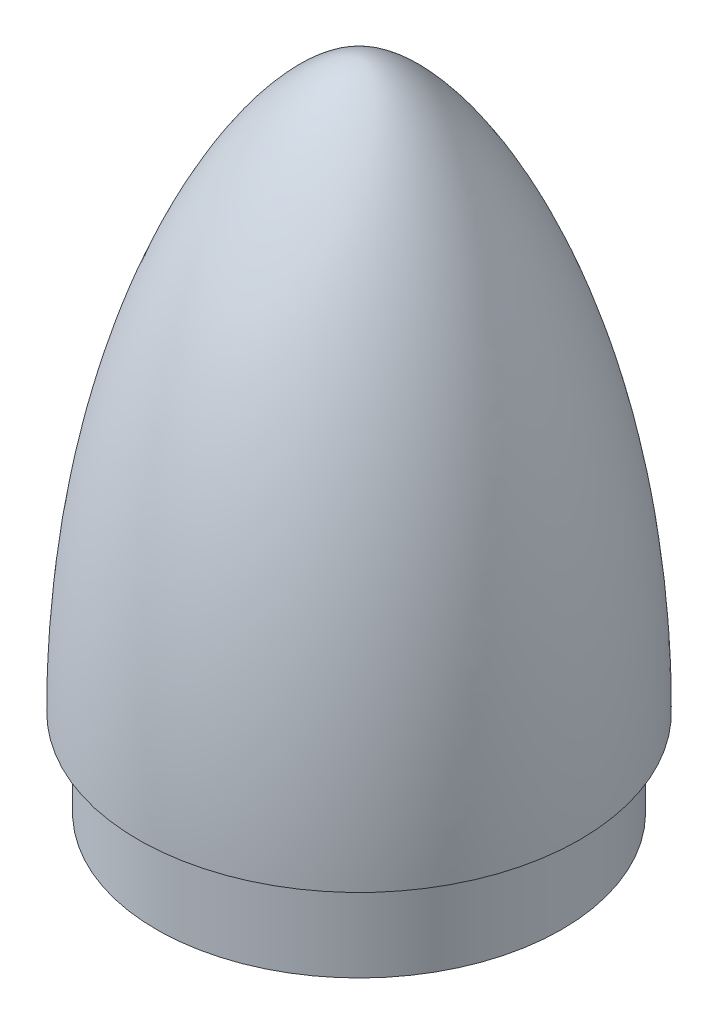
from build123d import *

# Parameters (mm, degrees)
THICKEN1_T1         = 1.2
BOSS_EXTRUDE7_REACH = 75.217
SKETCH5_W           = 21
SKETCH5_H           = 3.5
CUT_EXTRUDE1_DEPTH  = 2


with BuildPart() as body_1:
    # Surface-Revolve1: a surface, the sketch's curves turned about an axis
    with BuildLine(Plane.XY, mode=Mode.PRIVATE) as surface_revolve1_1_path:
        Line((23.3, 0), (23.3, 10))
        Line((23.3, 10), (25.4, 10))
        add(Edge.make_bspline(
            [(25.4, 10), (25.4, 50), (8.333333333, 75), (0, 75)],
            knots=[0, 0, 0, 0, 1, 1, 1, 1], degree=3))
    surface_revolve1_1 = Shell.revolve(surface_revolve1_1_path.wire(), 360, Axis((0, 75, 0), (0, -1, 0)))
    add(Solid.thicken(surface_revolve1_1, THICKEN1_T1))

    # Sketch4 → Boss-Extrude7 (add, up to next)
    with BuildSketch(Plane.XZ.offset(-11.2), mode=Mode.PRIVATE) as boss_extrude7_sk1:
        with BuildLine():
            Line((-24.174148432, 1), (24.174148432, 1))
            ThreePointArc((24.174148432, 1), (24.194822843, 0), (24.174148432, -1))
            Line((24.174148432, -1), (-24.174148432, -1))
            ThreePointArc((-24.174148432, -1), (-24.194822843, 0), (-24.174148432, 1))
        make_face()
    boss_extrude7_tool1 = extrude(boss_extrude7_sk1.sketch, amount=-BOSS_EXTRUDE7_REACH, mode=Mode.PRIVATE) - body_1.part
    add(boss_extrude7_tool1.solids().sort_by_distance((0, 11.2, 0))[0])

    # Sketch5 → Cut-Extrude1 (cut)
    with BuildSketch(Plane.XY.offset(1)):
        with Locations((0, 41)):
            Rectangle(SKETCH5_W, SKETCH5_H)
        with Locations((0, 20)):
            Rectangle(SKETCH5_W, SKETCH5_H)
    extrude(amount=-CUT_EXTRUDE1_DEPTH, mode=Mode.SUBTRACT)


solid = body_1.part
